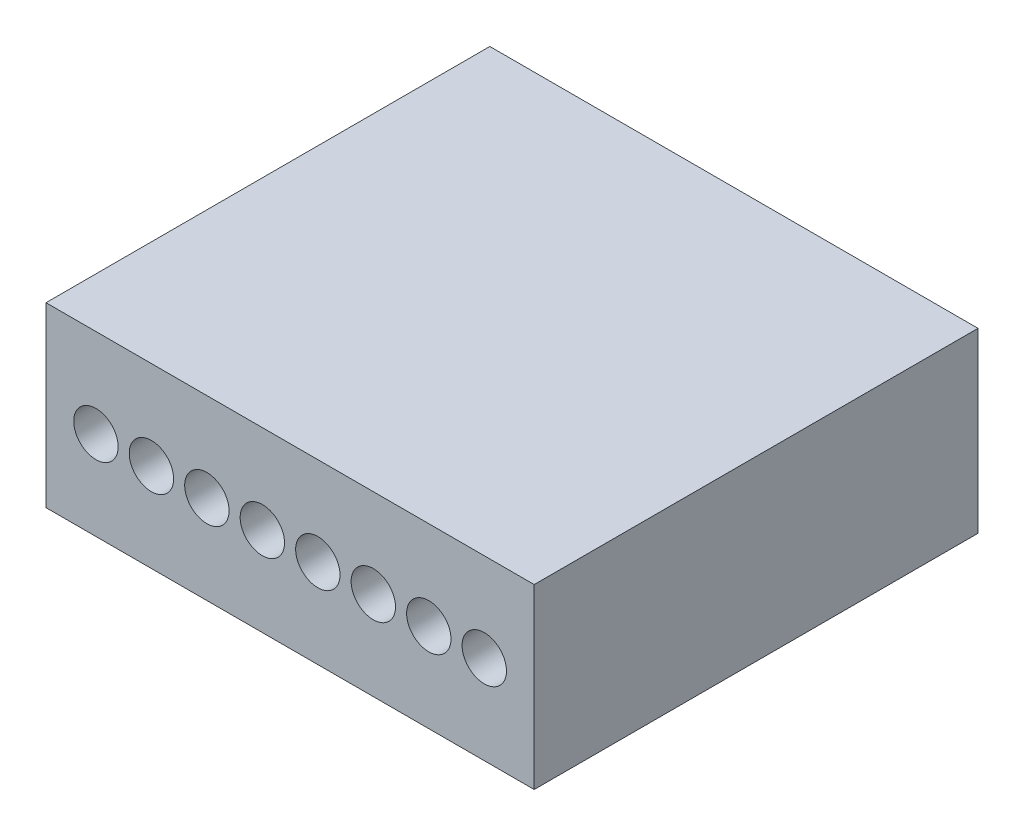
from build123d import *

# Parameters (mm, degrees)
SKETCH2_W           = 11
SKETCH2_H           = 4
BOSS_EXTRUDE1_DEPTH = 10
SKETCH3_R           = 0.5
CUT_EXTRUDE1_DEPTH  = 5


with BuildPart() as part:
    # Sketch2 → Boss-Extrude1 (new body)
    with BuildSketch(Plane.XY):
        with Locations((5.5, 2)):
            Rectangle(SKETCH2_W, SKETCH2_H)
    extrude(amount=BOSS_EXTRUDE1_DEPTH)

    # Sketch3 → Cut-Extrude1 (cut)
    with BuildSketch(Plane.XY.offset(10)):
        with Locations((1.125, 2)):
            Circle(SKETCH3_R)
        with Locations((2.375, 2)):
            Circle(SKETCH3_R)
        with Locations((3.625, 2)):
            Circle(SKETCH3_R)
        with Locations((4.875, 2)):
            Circle(SKETCH3_R)
        with Locations((6.125, 2)):
            Circle(SKETCH3_R)
        with Locations((7.375, 2)):
            Circle(SKETCH3_R)
        with Locations((8.625, 2)):
            Circle(SKETCH3_R)
        with Locations((9.875, 2)):
            Circle(SKETCH3_R)
    extrude(amount=-CUT_EXTRUDE1_DEPTH, mode=Mode.SUBTRACT)


solid = part.part
